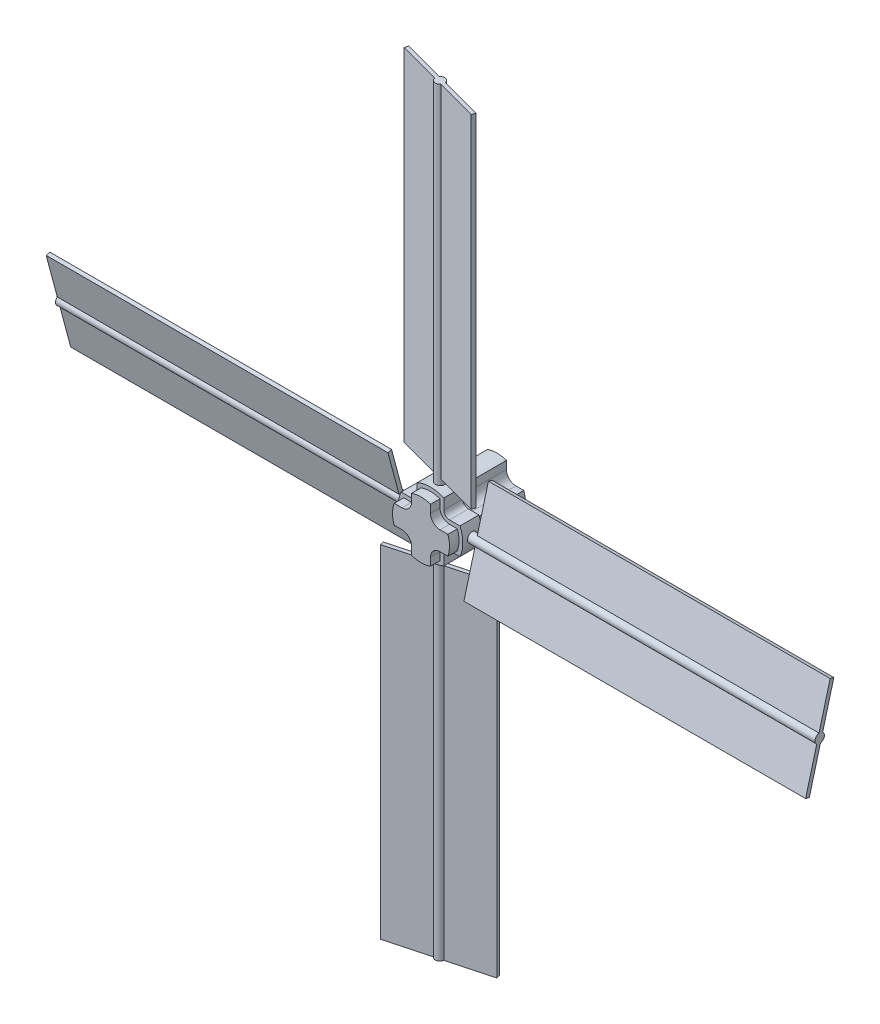
from build123d import *

# Parameters (mm, degrees)
BOSS_EXTRUDE1_DEPTH = 400
CIRPATTERN1_COUNT   = 4
FILLET1_R           = 50
BOSS_EXTRUDE2_START = -50
BOSS_EXTRUDE2_DEPTH = 100
SKETCH3_R           = 25
BOSS_EXTRUDE3_DEPTH = 2000
EXTRUDE_THIN1_START = 200
EXTRUDE_THIN1_DEPTH = 1800
CIRPATTERN2_COUNT   = 4


with BuildPart() as part:
    # Sketch1 → Boss-Extrude1 (new body)
    with BuildSketch(Plane(origin=(0, 0, 0), x_dir=(0, 1, 0), z_dir=(0, 0, 1))):
        with BuildLine():
            Line((-50, 141.421356237), (-50, 0))
            Line((-50, 0), (50, 0))
            Line((50, 0), (50, 141.421356237))
            ThreePointArc((50, 141.421356237), (0, 150), (-50, 141.421356237))
        make_face()
    extrude(amount=BOSS_EXTRUDE1_DEPTH)


with BuildPart() as cirpattern1_1:
    # CirPattern1: pattern copy
    add(part.part.rotate(Axis((0, 0, 0), (0, 0, 1)), 1 * 360 / CIRPATTERN1_COUNT))


with BuildPart() as cirpattern1_2:
    # CirPattern1: pattern copy
    add(part.part.rotate(Axis((0, 0, 0), (0, 0, 1)), 2 * 360 / CIRPATTERN1_COUNT))


with BuildPart() as cirpattern1_3:
    # CirPattern1: pattern copy
    add(part.part.rotate(Axis((0, 0, 0), (0, 0, 1)), 3 * 360 / CIRPATTERN1_COUNT))


with BuildPart() as part_1:
    add(part.part)

    # Combine1: union CirPattern1_1, CirPattern1_2, CirPattern1_3
    add(cirpattern1_1.part)
    add(cirpattern1_2.part)
    add(cirpattern1_3.part)

    # Fillet1
    fillet1_edges = [part_1.edges().sort_by_distance(p)[0] for p in [
        (-50, 50, 200),
        (-50, -50, 200),
        (50, -50, 200),
        (50, 50, 200),
    ]]
    fillet(fillet1_edges, radius=FILLET1_R)

    # Sketch2 → Boss-Extrude2 (add)
    with BuildSketch(Plane.XY.offset(400).offset(BOSS_EXTRUDE2_START)):
        with BuildLine():
            Line((-70, 154.919333848), (-70, 100))
            ThreePointArc((-70, 100), (-78.786796564, 78.786796564), (-100, 70))
            Line((-100, 70), (-154.919333848, 70))
            ThreePointArc((-154.919333848, 70), (-170, 0), (-154.919333848, -70))
            Line((-154.919333848, -70), (-100, -70))
            ThreePointArc((-100, -70), (-78.786796564, -78.786796564), (-70, -100))
            Line((-70, -100), (-70, -154.919333848))
            ThreePointArc((-70, -154.919333848), (0, -170), (70, -154.919333848))
            Line((70, -154.919333848), (70, -100))
            ThreePointArc((70, -100), (78.786796564, -78.786796564), (100, -70))
            Line((100, -70), (154.919333848, -70))
            ThreePointArc((154.919333848, -70), (170, 0), (154.919333848, 70))
            Line((154.919333848, 70), (100, 70))
            ThreePointArc((100, 70), (78.786796564, 78.786796564), (70, 100))
            Line((70, 100), (70, 154.919333848))
            ThreePointArc((70, 154.919333848), (0, 170), (-70, 154.919333848))
        make_face()
    extrude(amount=-BOSS_EXTRUDE2_DEPTH)


with BuildPart() as body_2:
    # Sketch3 → Boss-Extrude3 (new body)
    with BuildSketch(Plane(origin=(0, 0, 0), x_dir=(-1, 0, 0), z_dir=(0, 1, 0))):
        with Locations((0, 300)):
            Circle(SKETCH3_R)
    extrude(amount=BOSS_EXTRUDE3_DEPTH)

    # Sketch3_3 → Extrude-Thin1 (add)
    with BuildSketch(Plane(origin=(0, 0, 0), x_dir=(-1, 0, 0), z_dir=(0, 1, 0)).offset(EXTRUDE_THIN1_START)):
        Polygon((-244.069647023, 355.045503013), (238.893266121, 225.635980461), (244.069647023, 244.954496987), (-238.893266121, 374.364019539), align=None)
    extrude(amount=EXTRUDE_THIN1_DEPTH)


with BuildPart() as cirpattern2_1:
    # CirPattern2: pattern copy
    add(body_2.part.rotate(Axis((0, 0, 0), (0, 0, 1)), 1 * 360 / CIRPATTERN2_COUNT))


with BuildPart() as cirpattern2_2:
    # CirPattern2: pattern copy
    add(body_2.part.rotate(Axis((0, 0, 0), (0, 0, 1)), 2 * 360 / CIRPATTERN2_COUNT))


with BuildPart() as cirpattern2_3:
    # CirPattern2: pattern copy
    add(body_2.part.rotate(Axis((0, 0, 0), (0, 0, 1)), 3 * 360 / CIRPATTERN2_COUNT))


with BuildPart() as part_2:
    add(part_1.part)

    # Combine2: union body 2, CirPattern2_1, CirPattern2_2, CirPattern2_3
    add(body_2.part)
    add(cirpattern2_1.part)
    add(cirpattern2_2.part)
    add(cirpattern2_3.part)


solid = part_2.part
